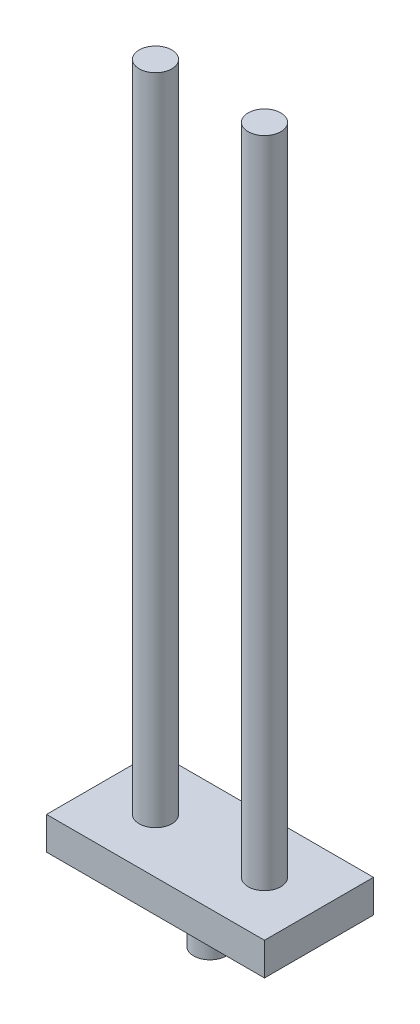
from build123d import *

# Parameters (mm, degrees)
SKETCH1_W           = 20
SKETCH1_H           = 10
BOSS_EXTRUDE1_DEPTH = 3
SKETCH2_R           = 1.5
BOSS_EXTRUDE2_DEPTH = 60
SKETCH3_R           = 1.5
BOSS_EXTRUDE3_DEPTH = 5


with BuildPart() as part:
    # Sketch1 → Boss-Extrude1 (new body)
    with BuildSketch(Plane(origin=(0, 0, 0), x_dir=(1, 0, 0), z_dir=(0, 1, 0))):
        Rectangle(SKETCH1_W, SKETCH1_H)
    extrude(amount=BOSS_EXTRUDE1_DEPTH)

    # Sketch2 → Boss-Extrude2 (add)
    with BuildSketch(Plane(origin=(0, 3, 0), x_dir=(1, 0, 0), z_dir=(0, 1, 0))):
        with Locations((-5, 0)):
            Circle(SKETCH2_R)
        with Locations((5, 0)):
            Circle(SKETCH2_R)
    extrude(amount=BOSS_EXTRUDE2_DEPTH)

    # Sketch3 → Boss-Extrude3 (add)
    with BuildSketch(Plane.XZ):
        Circle(SKETCH3_R)
    extrude(amount=BOSS_EXTRUDE3_DEPTH)


solid = part.part
